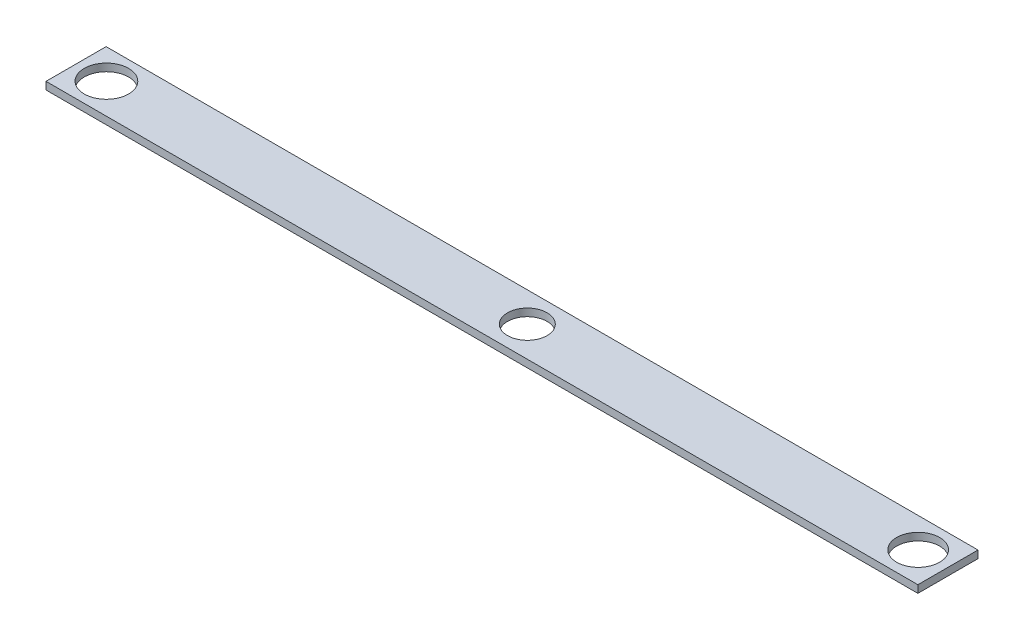
from build123d import *

# Parameters (mm, degrees)
SKETCH2_W           = 184.15
SKETCH2_H           = 12.7
SKETCH2_R           = 4.181180969
SKETCH2_R_2         = 4.536454583
SKETCH2_R_3         = 4.688788017
BOSS_EXTRUDE1_DEPTH = 1.5875


with BuildPart() as part:
    # Sketch2 → Boss-Extrude1 (new body)
    with BuildSketch(Plane(origin=(0, 0, 0), x_dir=(1, 0, 0), z_dir=(0, 1, 0))):
        with Locations((-3.175, -0.059345794)):
            Rectangle(SKETCH2_W, SKETCH2_H)
        Circle(SKETCH2_R, mode=Mode.SUBTRACT)
        with Locations((82.55, 0)):
            Circle(SKETCH2_R_2, mode=Mode.SUBTRACT)
        with Locations((-88.9, 0)):
            Circle(SKETCH2_R_3, mode=Mode.SUBTRACT)
    extrude(amount=BOSS_EXTRUDE1_DEPTH)


solid = part.part
